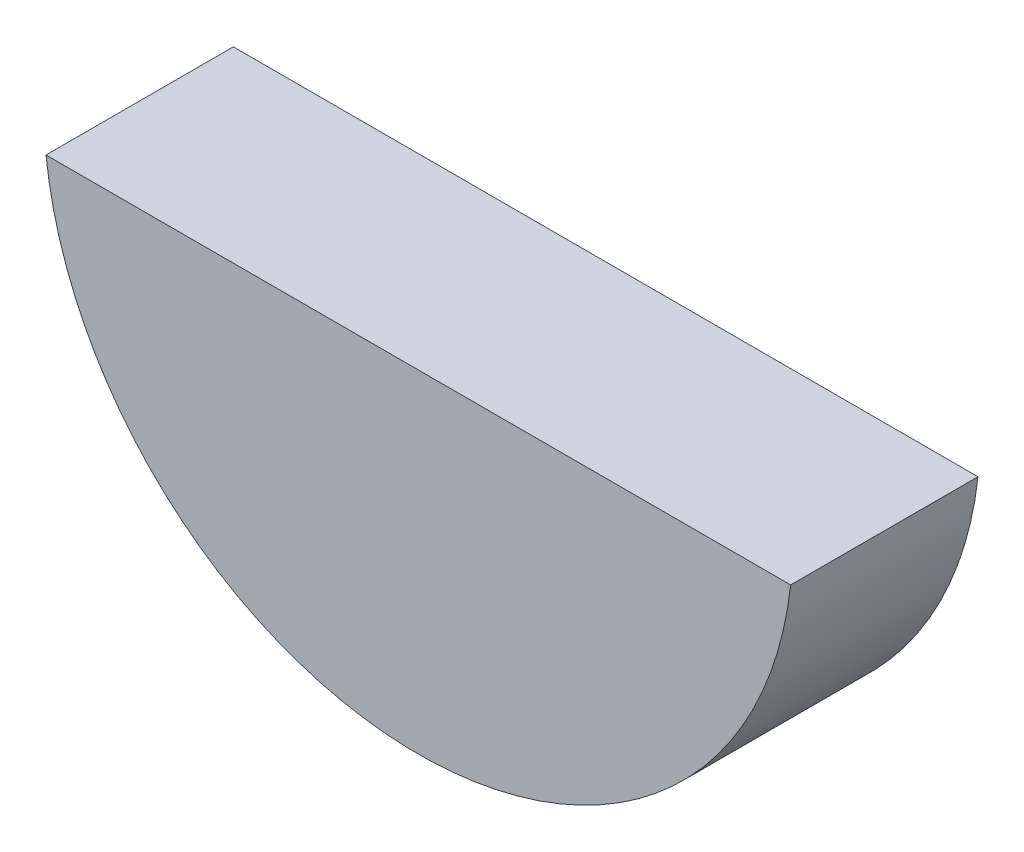
from build123d import *

# Parameters (mm, degrees)
SKETCH1_R      = 3.175
EXTRUDE1_DEPTH = 1.5875
EXTRUDE2_DEPTH = 2.5875


with BuildPart() as part:
    # Sketch1 → Extrude1 (new body)
    with BuildSketch(Plane.XY):
        Circle(SKETCH1_R)
    extrude(amount=EXTRUDE1_DEPTH)

    # Sketch2 → Extrude2 (cut, through all)
    with BuildSketch(Plane.XY.offset(1.5875)):
        with BuildLine():
            Line((-3.155070197, -0.355185939), (3.155070197, -0.355185939))
            ThreePointArc((3.155070197, -0.355185939), (0, 3.175), (-3.155070197, -0.355185939))
        make_face()
    extrude(amount=-EXTRUDE2_DEPTH, mode=Mode.SUBTRACT)


solid = part.part
